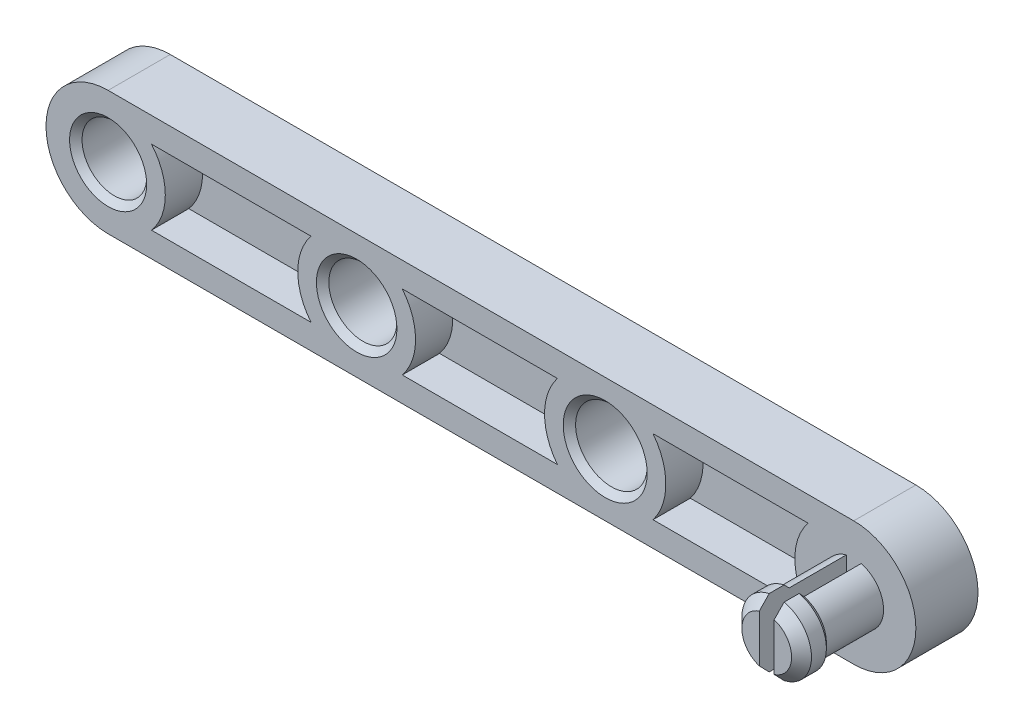
from build123d import *

# Parameters (mm, degrees)
BOSS_EXTRUDE1_DEPTH = 6.35
SKETCH2_R           = 3.302
SKETCH2_R_2         = 3.4798
SKETCH2_R_3         = 3.6576
CUT_EXTRUDE1_DEPTH  = 7.35
SHELL5_T            = -2.54
SKETCH5_R           = 6.0198
BOSS_EXTRUDE5_DEPTH = 3.81
SKETCH8_W           = 1.524
SKETCH8_H           = 8.89
CUT_EXTRUDE2_DEPTH  = 6.35
CHAMFER1_SIZE       = 0.635


with BuildPart() as part:
    # Sketch1 → Boss-Extrude1 (new body)
    with BuildSketch(Plane.XY):
        with BuildLine():
            Line((-38.1, 6.35), (38.1, 6.35))
            ThreePointArc((38.1, 6.35), (44.45, 0), (38.1, -6.35))
            Line((38.1, -6.35), (-38.1, -6.35))
            ThreePointArc((-38.1, -6.35), (-44.45, 0), (-38.1, 6.35))
        make_face()
    extrude(amount=BOSS_EXTRUDE1_DEPTH)

    # Sketch2 → Cut-Extrude1 (cut, through all)
    with BuildSketch(Plane.XY.offset(6.35)):
        with Locations((-38.1, 0)):
            Circle(SKETCH2_R)
        with Locations((-12.7, 0)):
            Circle(SKETCH2_R_2)
        with Locations((12.7, 0)):
            Circle(SKETCH2_R_3)
    extrude(amount=-CUT_EXTRUDE1_DEPTH, mode=Mode.SUBTRACT)

    # Shell5
    shell5_openings = [part.faces().sort_by_distance(p)[0] for p in [
        (1.279901808, 0, 6.35),
    ]]
    offset(amount=SHELL5_T, openings=shell5_openings)

    # Sketch5 → Boss-Extrude5 (add)
    with BuildSketch(Plane.XY.offset(2.54)):
        with Locations((38.1, 0)):
            Circle(SKETCH5_R)
    extrude(amount=BOSS_EXTRUDE5_DEPTH)

    # Sketch7 → Revolve1 (revolve)
    with BuildSketch(Plane(origin=(0, 0, 0), x_dir=(1, 0, 0), z_dir=(0, 1, 0))):
        Polygon((35.052, -6.35), (35.052, -12.192), (34.544, -12.7), (34.544, -14.224), (35.56, -15.24), (38.1, -15.24), (38.1, -6.35), align=None)
    revolve(axis=Axis((38.1, 0, 0), (0, 0, 1)))

    # Sketch8 → Cut-Extrude2 (cut, symmetric)
    with BuildSketch(Plane(origin=(0, 0, 0), x_dir=(1, 0, 0), z_dir=(0, 1, 0))):
        with Locations((38.1, -10.795)):
            Rectangle(SKETCH8_W, SKETCH8_H)
    extrude(amount=CUT_EXTRUDE2_DEPTH, both=True, mode=Mode.SUBTRACT)

    # Chamfer1
    chamfer1_edges = [part.edges().sort_by_distance(p)[0] for p in [
        (-41.402, 0, 6.35),
        (-16.1798, 0, 6.35),
        (9.0424, 0, 6.35),
    ]]
    chamfer(chamfer1_edges, length=CHAMFER1_SIZE)


solid = part.part
